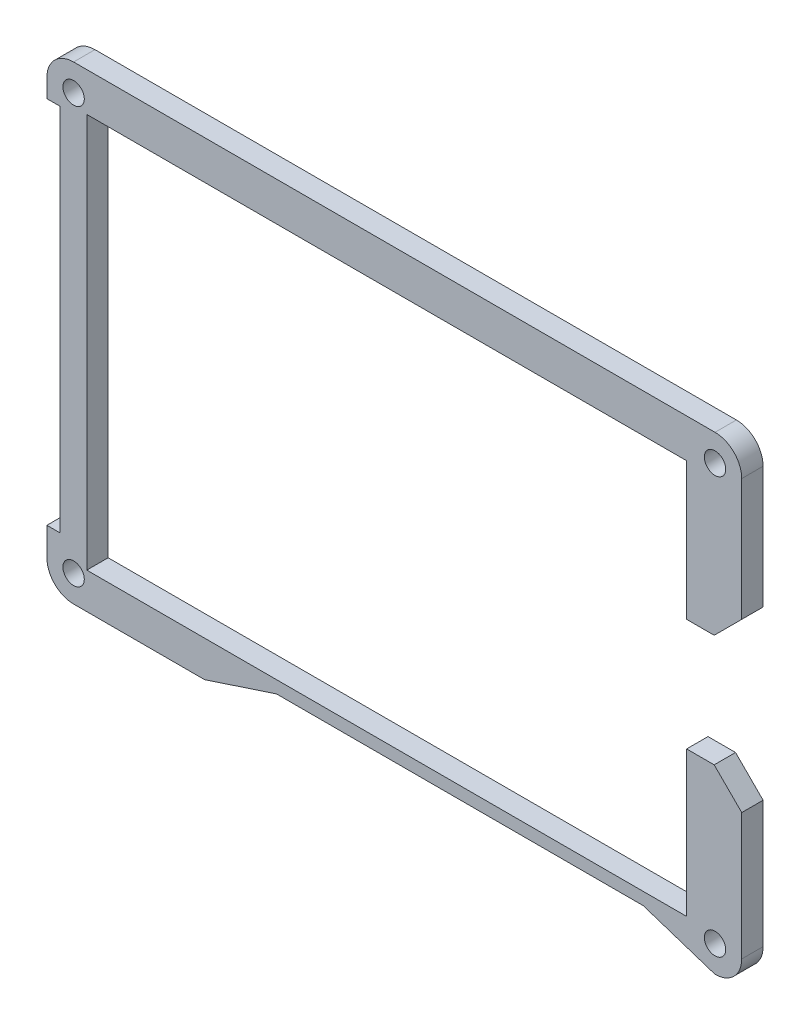
from build123d import *

# Parameters (mm, degrees)
SKETCH1_R           = 1.3462
SKETCH1_W           = 3.7846
SKETCH1_H           = 52.6961
BOSS_EXTRUDE1_DEPTH = 3.048
SKETCH2_R           = 1.524
CUT_EXTRUDE1_DEPTH  = 4.048
CUT_EXTRUDE2_DEPTH  = 4.048


with BuildPart() as part:
    # Sketch1 → Boss-Extrude1 (new body)
    with BuildSketch(Plane.XY):
        with BuildLine():
            Line((-401.0571, 150.956597849), (-401.0571, 148.341))
            Line((-401.0571, 148.341), (-399.1521, 148.341))
            Line((-399.1521, 148.341), (-395.3675, 148.341))
            Line((-395.3675, 148.341), (-395.3675, 149.2432))
            Line((-395.3675, 149.2432), (-309.8086, 149.2432))
            Line((-309.8086, 149.2432), (-309.8086, 128.8851))
            Line((-309.8086, 128.8851), (-305.87795, 128.8851))
            Line((-305.87795, 128.8851), (-301.9473, 132.81575))
            Line((-301.9473, 132.81575), (-301.9473, 150.9704))
            ThreePointArc((-301.9473, 150.9704), (-303.063223164, 153.664476836), (-305.7573, 154.7804))
            Line((-305.7573, 154.7804), (-397.247125, 154.7804))
            ThreePointArc((-397.247125, 154.7804), (-399.946077222, 153.659592612), (-401.0571, 150.956597849))
        make_face()
        with Locations((-397.247125, 150.9704)):
            Circle(SKETCH1_R, mode=Mode.SUBTRACT)
        with Locations((-305.7573, 150.9704)):
            Circle(SKETCH1_R, mode=Mode.SUBTRACT)
        with Locations((-397.2598, 121.99295)):
            Rectangle(SKETCH1_W, SKETCH1_H)
        with BuildLine():
            Line((-395.3675, 95.6449), (-399.1521, 95.6449))
            Line((-399.1521, 95.6449), (-401.0571, 95.6449))
            Line((-401.0571, 95.6449), (-401.0571, 91.659304166))
            ThreePointArc((-401.0571, 91.659304166), (-399.951018769, 88.947400452), (-397.2472, 87.8217))
            Line((-397.2472, 87.8217), (-378.5565, 87.8217))
            Line((-378.5565, 87.8217), (-368.3165, 91.1883))
            Line((-368.3165, 91.1883), (-315.9973, 91.1883))
            Line((-315.9973, 91.1883), (-305.7573, 87.8217))
            ThreePointArc((-305.7573, 87.8217), (-303.063223164, 88.937623164), (-301.9473, 91.6317))
            Line((-301.9473, 91.6317), (-301.9473, 111.74645))
            Line((-301.9473, 111.74645), (-305.87795, 115.6771))
            Line((-305.87795, 115.6771), (-309.8086, 115.6771))
            Line((-309.8086, 115.6771), (-309.8086, 92.9525))
            Line((-309.8086, 92.9525), (-395.3675, 92.9525))
            Line((-395.3675, 92.9525), (-395.3675, 95.6449))
        make_face()
        with Locations((-397.2472, 91.6317)):
            Circle(SKETCH1_R, mode=Mode.SUBTRACT)
        with Locations((-305.7573, 91.6317)):
            Circle(SKETCH1_R, mode=Mode.SUBTRACT)
    extrude(amount=BOSS_EXTRUDE1_DEPTH)

    # Sketch2 → Cut-Extrude1 (cut, through all)
    with BuildSketch(Plane(origin=(0, 0, 0), x_dir=(-1, 0, 0), z_dir=(0, 0, -1))):
        with Locations((305.7573, 150.9704)):
            Circle(SKETCH2_R)
        with Locations((305.7573, 91.6317)):
            Circle(SKETCH2_R)
        with Locations((397.2472, 91.6317)):
            Circle(SKETCH2_R)
        with Locations((397.247125, 150.9704)):
            Circle(SKETCH2_R)
    extrude(amount=-CUT_EXTRUDE1_DEPTH, mode=Mode.SUBTRACT)

    # Sketch3 → Cut-Extrude2 (cut, through all)
    with BuildSketch(Plane.XY.offset(3.048)):
        Polygon((-309.8086, 129.6471), (-309.8086, 128.8851), (-305.87795, 128.8851), (-301.9473, 132.81575), (-301.9473, 133.57775), (-305.87795, 129.6471), align=None)
        Polygon((-305.87795, 115.6771), (-309.8086, 115.6771), (-309.8086, 113.6451), (-305.87795, 113.6451), (-301.9473, 109.71445), (-301.9473, 111.74645), align=None)
    extrude(amount=-CUT_EXTRUDE2_DEPTH, mode=Mode.SUBTRACT)


solid = part.part
